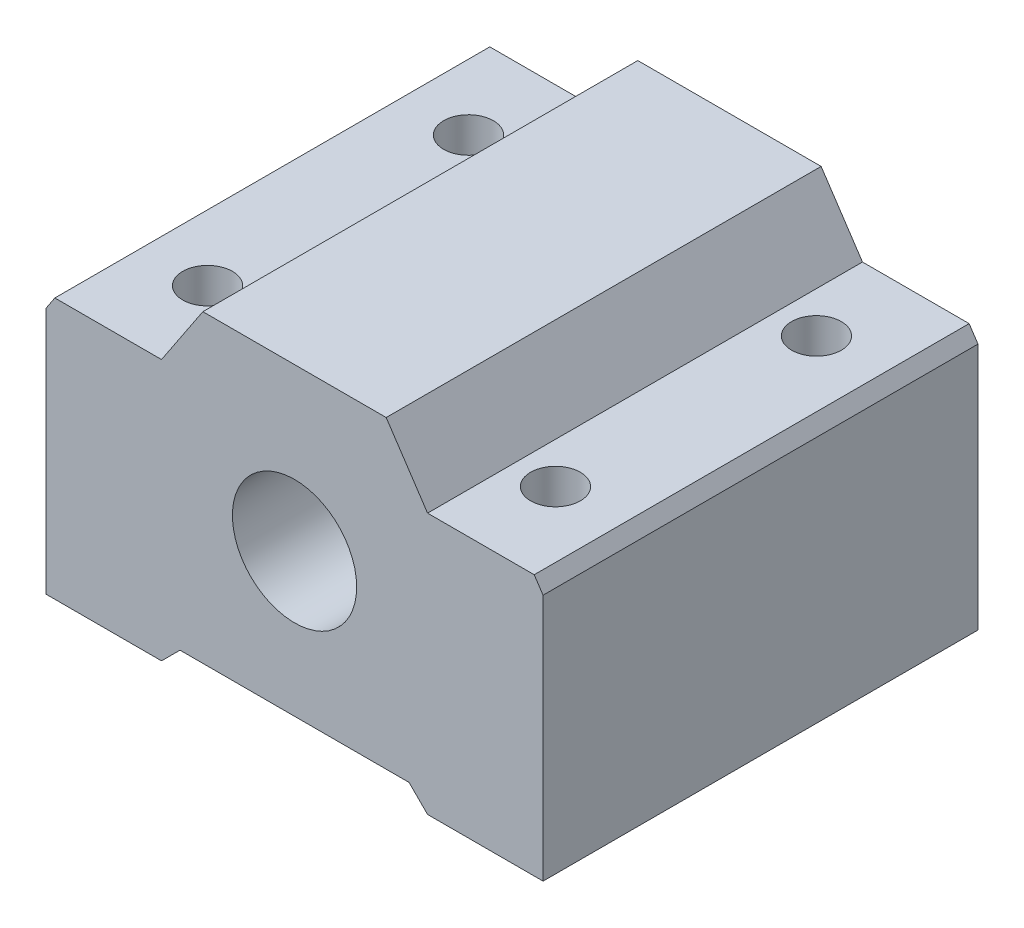
from build123d import *

# Parameters (mm, degrees)
SKETCH1_R           = 5
BOSS_EXTRUDE1_DEPTH = 35
CUT_EXTRUDE1_REACH  = 28
SKETCH2_R           = 2


with BuildPart() as part:
    # Sketch1 → Boss-Extrude1 (new body)
    with BuildSketch(Plane.XY):
        Polygon((-7.376347734, 13), (-10.704853009, 8), (-19.287228785, 8), (-20, 6.929292346), (-20, -13), (-12.193167268, -13), (-10.704853009, -13), (-9.216538749, -11.511685741), (9.216538749, -11.511685741), (10.704853009, -13), (12.193167268, -13), (20, -13), (20, 6.929292346), (19.287228785, 8), (10.704853009, 8), (7.376347734, 13), align=None)
        Circle(SKETCH1_R, mode=Mode.SUBTRACT)
    extrude(amount=BOSS_EXTRUDE1_DEPTH)

    # Sketch2 → Cut-Extrude1 (cut, up to next)
    with BuildSketch(Plane.XZ.offset(13), mode=Mode.PRIVATE) as cut_extrude1_sk1:
        with Locations((-14, 28)):
            Circle(SKETCH2_R)
    cut_extrude1_tool1 = extrude(cut_extrude1_sk1.sketch, amount=-CUT_EXTRUDE1_REACH, mode=Mode.PRIVATE) & part.part
    add(cut_extrude1_tool1.solids().sort_by_distance((-14, -13, 28))[0], mode=Mode.SUBTRACT)
    # Sketch2 → Cut-Extrude1 (cut, up to next)
    with BuildSketch(Plane.XZ.offset(13), mode=Mode.PRIVATE) as cut_extrude1_sk2:
        with Locations((14, 28)):
            Circle(SKETCH2_R)
    cut_extrude1_tool2 = extrude(cut_extrude1_sk2.sketch, amount=-CUT_EXTRUDE1_REACH, mode=Mode.PRIVATE) & part.part
    add(cut_extrude1_tool2.solids().sort_by_distance((14, -13, 28))[0], mode=Mode.SUBTRACT)
    # Sketch2 → Cut-Extrude1 (cut, up to next)
    with BuildSketch(Plane.XZ.offset(13), mode=Mode.PRIVATE) as cut_extrude1_sk3:
        with Locations((14, 7)):
            Circle(SKETCH2_R)
    cut_extrude1_tool3 = extrude(cut_extrude1_sk3.sketch, amount=-CUT_EXTRUDE1_REACH, mode=Mode.PRIVATE) & part.part
    add(cut_extrude1_tool3.solids().sort_by_distance((14, -13, 7))[0], mode=Mode.SUBTRACT)
    # Sketch2 → Cut-Extrude1 (cut, up to next)
    with BuildSketch(Plane.XZ.offset(13), mode=Mode.PRIVATE) as cut_extrude1_sk4:
        with Locations((-14, 7)):
            Circle(SKETCH2_R)
    cut_extrude1_tool4 = extrude(cut_extrude1_sk4.sketch, amount=-CUT_EXTRUDE1_REACH, mode=Mode.PRIVATE) & part.part
    add(cut_extrude1_tool4.solids().sort_by_distance((-14, -13, 7))[0], mode=Mode.SUBTRACT)


solid = part.part
